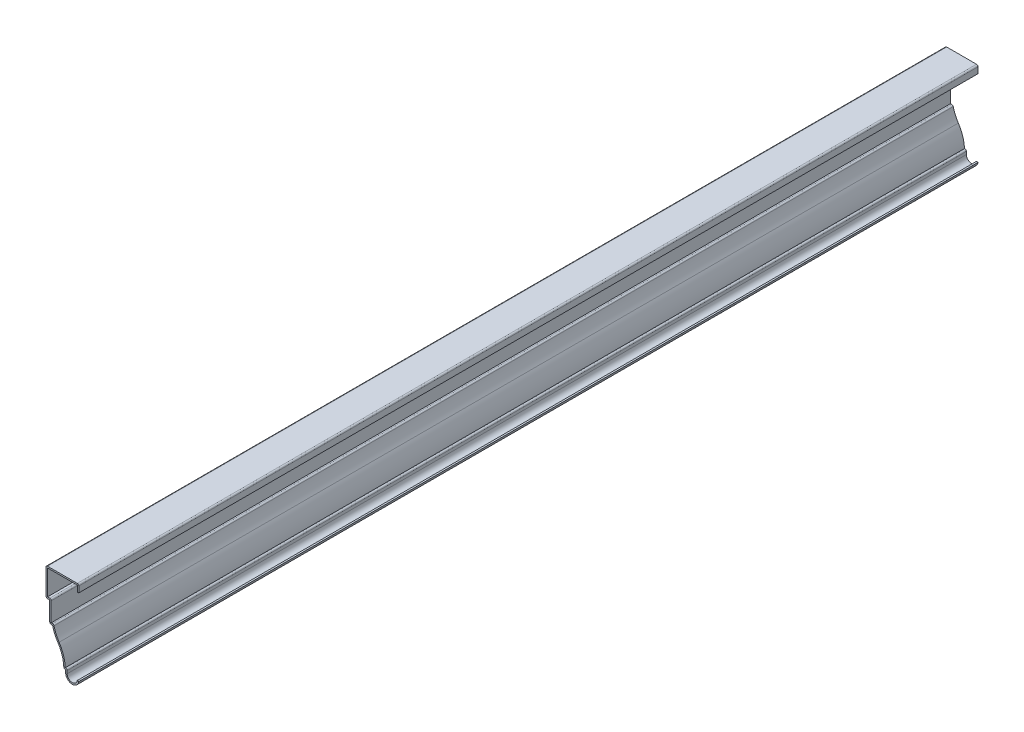
from build123d import *

# Parameters (mm, degrees)
EXTRUDE_THIN1_DEPTH = 762
FILLET1_R           = 1.27


with BuildPart() as part:
    # Sketch1 → Extrude-Thin1 (new body)
    with BuildSketch(Plane.XY):
        with BuildLine():
            ThreePointArc((0, 4.7625), (-5.938970367, 0.015308043), (-11.1125, 5.586824141))
            Line((-11.1125, 5.586824141), (-11.1125, 7.9375))
            Line((-11.1125, 7.9375), (-12.7, 7.9375))
            ThreePointArc((-12.7, 7.9375), (-13.982491679, 16.639311629), (-17.720905139, 24.60113148))
            ThreePointArc((-17.720905139, 24.60113148), (-20.42299298, 29.566722219), (-22.225, 34.925))
            Line((-22.225, 34.925), (-24.60625, 34.925))
            Line((-24.60625, 34.925), (-24.60625, 52.3875))
            Line((-24.60625, 52.3875), (-27.78125, 52.3875))
            Line((-27.78125, 52.3875), (-27.78125, 76.2))
            Line((-27.78125, 76.2), (0, 76.2))
            Line((0, 76.2), (0, 69.85))
            Line((0, 69.85), (-1.27, 69.85))
            Line((-1.27, 69.85), (-1.27, 74.93))
            Line((-1.27, 74.93), (-26.51125, 74.93))
            Line((-26.51125, 74.93), (-26.51125, 53.6575))
            Line((-26.51125, 53.6575), (-23.33625, 53.6575))
            Line((-23.33625, 53.6575), (-23.33625, 36.195))
            Line((-23.33625, 36.195), (-21.209398438, 36.195))
            ThreePointArc((-21.209398438, 36.195), (-19.454378473, 30.532415703), (-16.662311672, 25.302758069))
            ThreePointArc((-16.662311672, 25.302758069), (-12.955869325, 17.611976621), (-11.455667045, 9.2075))
            Line((-11.455667045, 9.2075), (-9.8425, 9.2075))
            Line((-9.8425, 9.2075), (-9.8425, 5.586824141))
            ThreePointArc((-9.8425, 5.586824141), (-5.845020027, 1.28182821), (-1.256099738, 4.949885827))
            Line((-1.256099738, 4.949885827), (0, 4.7625))
        make_face()
    extrude(amount=-EXTRUDE_THIN1_DEPTH)

    # Fillet1
    fillet1_edges = [part.edges().sort_by_distance(p)[0] for p in [
        (-23.33625, 53.6575, -381),
        (-21.209398438, 36.195, -381),
        (-9.8425, 9.2075, -381),
        (-12.7, 7.9375, -381),
        (-24.60625, 34.925, -381),
        (-27.78125, 52.3875, -381),
        (-27.78125, 76.2, -381),
        (0, 76.2, -381),
    ]]
    fillet(fillet1_edges, radius=FILLET1_R)


solid = part.part
